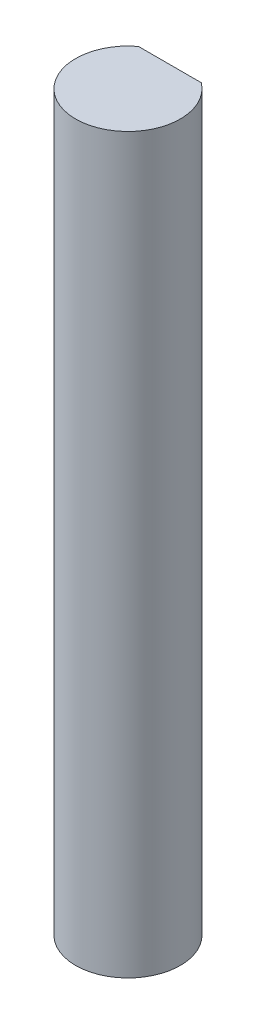
from build123d import *

# Parameters (mm, degrees)
BOSS_EXTRUDE1_DEPTH = 44.45


with BuildPart() as part:
    # Sketch1 → Boss-Extrude1 (new body)
    with BuildSketch(Plane(origin=(0, 0, 0), x_dir=(1, 0, 0), z_dir=(0, 1, 0))):
        with BuildLine():
            Line((-1.905, 2.54), (1.905, 2.54))
            ThreePointArc((1.905, 2.54), (0, -3.175), (-1.905, 2.54))
        make_face()
    extrude(amount=BOSS_EXTRUDE1_DEPTH)


solid = part.part
